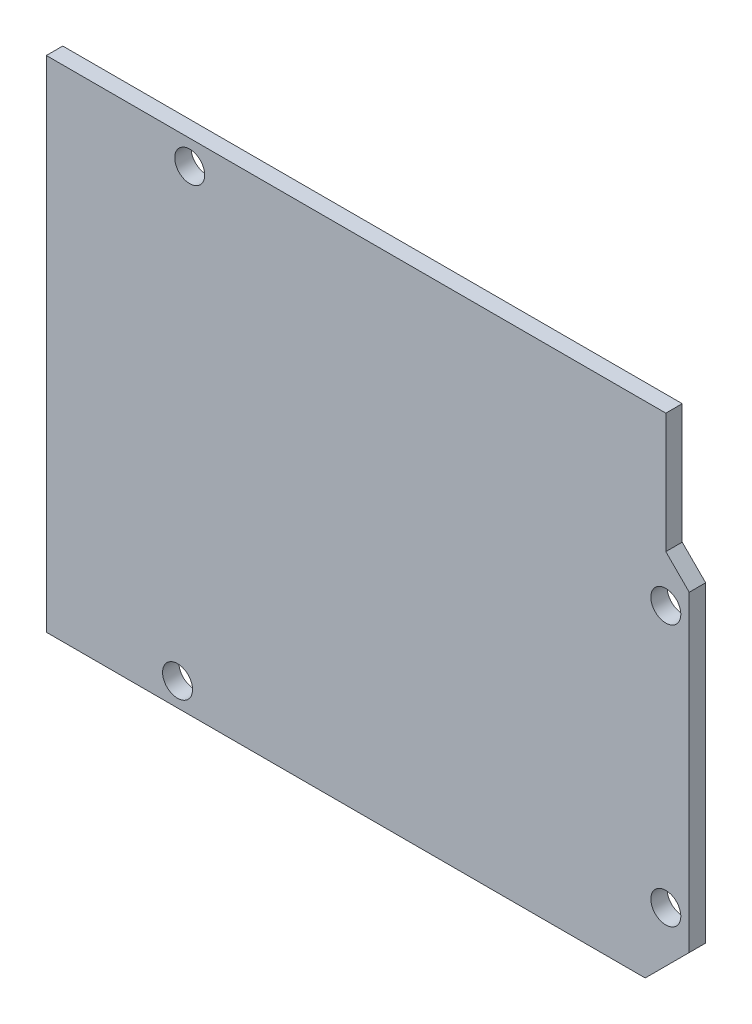
from build123d import *

# Parameters (mm, degrees)
SKETCH1_W           = 68.6
SKETCH1_H           = 53.3
BOSS_EXTRUDE1_DEPTH = 1.75
SKETCH2_R           = 1.6
CUT_EXTRUDE1_DEPTH  = 2.75
CUT_EXTRUDE2_DEPTH  = 2.75


with BuildPart() as part:
    # Sketch1 → Boss-Extrude1 (new body)
    with BuildSketch(Plane.XY):
        Rectangle(SKETCH1_W, SKETCH1_H)
    extrude(amount=BOSS_EXTRUDE1_DEPTH)

    # Sketch2 → Cut-Extrude1 (cut, through all)
    with BuildSketch(Plane.XY.offset(1.75)):
        with Locations((-19, 24.05)):
            Circle(SKETCH2_R)
        with Locations((-20.3, -24.15)):
            Circle(SKETCH2_R)
        with Locations((31.8, 8.85)):
            Circle(SKETCH2_R)
        with Locations((31.8, -19.05)):
            Circle(SKETCH2_R)
    extrude(amount=-CUT_EXTRUDE1_DEPTH, mode=Mode.SUBTRACT)

    # Sketch3 → Cut-Extrude2 (cut, through all)
    with BuildSketch(Plane.XY.offset(1.75)):
        Polygon((31.8, 26.65), (31.8, 13.85), (50.94988261, -5.29988261), (28.344966041, -27.904799179), (59.308885604, -27.904799179), (59.308885604, 26.65), align=None)
    extrude(amount=-CUT_EXTRUDE2_DEPTH, mode=Mode.SUBTRACT)


solid = part.part
